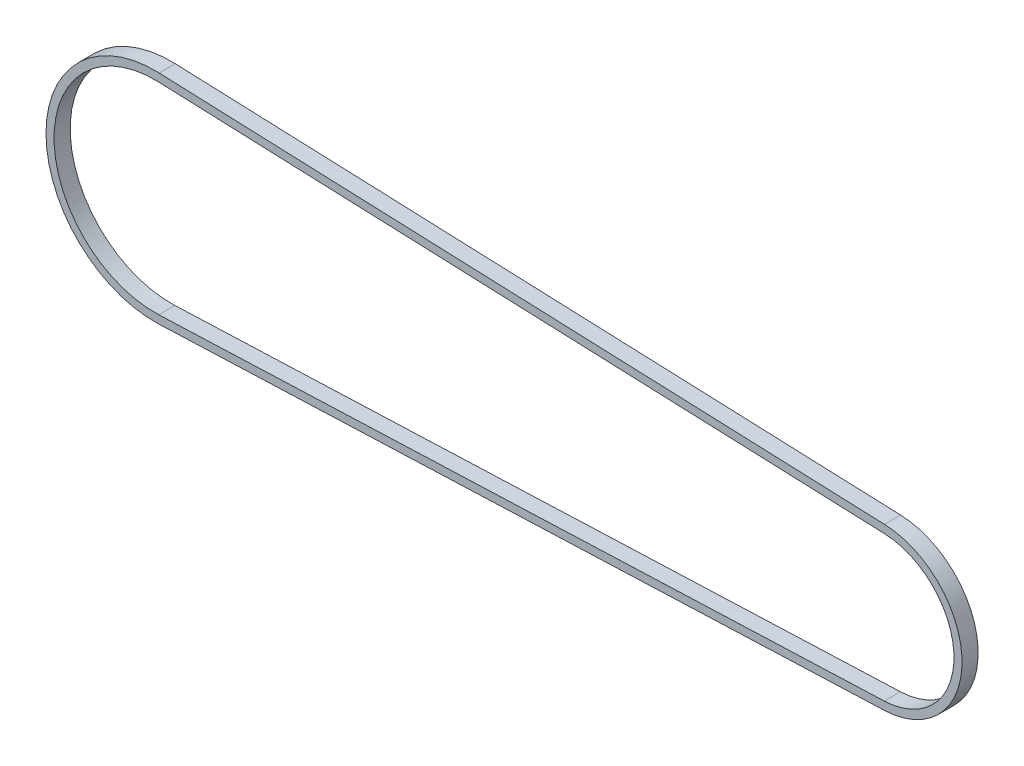
from build123d import *

# Parameters (mm, degrees)
EXTRUDE_THIN2_DEPTH = 10


with BuildPart() as part:
    # Sketch1 → Extrude-Thin2 (new body)
    with BuildSketch(Plane.XY):
        with BuildLine():
            Line((0.194297577, -49.996223419), (-449.805702423, -67.496223419))
            ThreePointArc((-449.805702423, -67.496223419), (-519.977798503, 0), (-449.805702423, 67.496223419))
            Line((-449.805702423, 67.496223419), (0.194297577, 49.996223419))
            ThreePointArc((0.194297577, 49.996223419), (48.284014922, 0), (0.194297577, -49.996223419))
        make_face()
        with BuildLine():
            Line((0, -45), (-450, -62.5))
            ThreePointArc((-450, -62.5), (-514.977798503, 0), (-450, 62.5))
            Line((-450, 62.5), (0, 45))
            ThreePointArc((0, 45), (43.284014922, 0), (0, -45))
        make_face(mode=Mode.SUBTRACT)
    extrude(amount=EXTRUDE_THIN2_DEPTH)


solid = part.part
